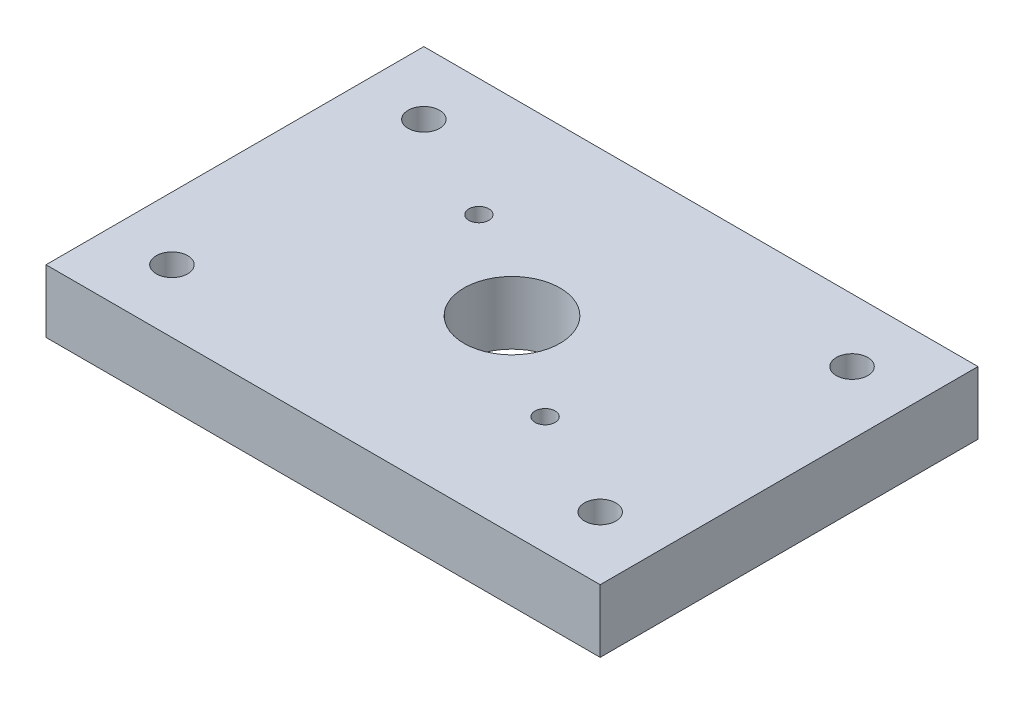
from build123d import *

# Parameters (mm, degrees)
SKETCH1_W           = 111.76
SKETCH1_H           = 76.2
SKETCH1_R           = 9.68375
SKETCH1_R_2         = 2.0193
SKETCH1_R_3         = 3.175
BOSS_EXTRUDE1_DEPTH = 12.7


with BuildPart() as part:
    # Sketch1 → Boss-Extrude1 (new body)
    with BuildSketch(Plane(origin=(0, 0, 0), x_dir=(1, 0, 0), z_dir=(0, 1, 0))):
        Rectangle(SKETCH1_W, SKETCH1_H)
        Circle(SKETCH1_R, mode=Mode.SUBTRACT)
        with Locations((-20.986174507, 14.308755346)):
            Circle(SKETCH1_R_2, mode=Mode.SUBTRACT)
        with Locations((20.986174507, -14.308755346)):
            Circle(SKETCH1_R_2, mode=Mode.SUBTRACT)
        with Locations((-43.18, 25.4)):
            Circle(SKETCH1_R_3, mode=Mode.SUBTRACT)
        with Locations((-43.18, -25.4)):
            Circle(SKETCH1_R_3, mode=Mode.SUBTRACT)
        with Locations((43.18, -25.4)):
            Circle(SKETCH1_R_3, mode=Mode.SUBTRACT)
        with Locations((43.18, 25.4)):
            Circle(SKETCH1_R_3, mode=Mode.SUBTRACT)
    extrude(amount=BOSS_EXTRUDE1_DEPTH)


solid = part.part
